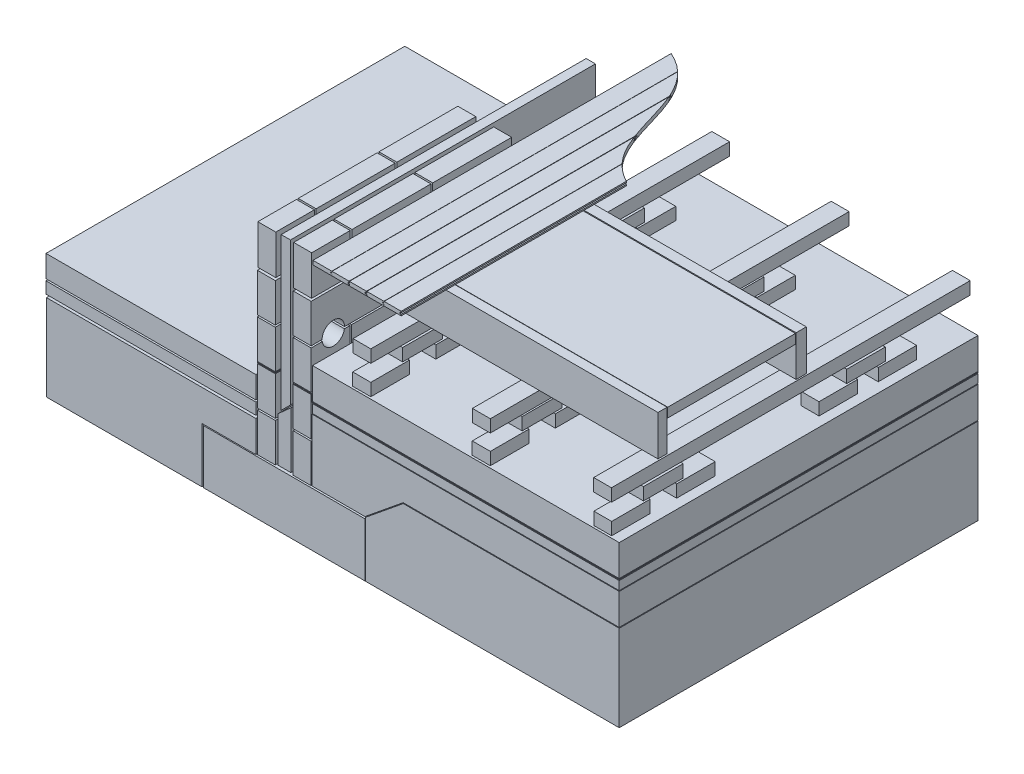
from build123d import *

# Parameters (mm, degrees)
SKETCH1_W         = 900
SKETCH1_H         = 300
EXTRUDE1_DEPTH    = 2000
SKETCH2_W         = 100
SKETCH2_H         = 215
EXTRUDE2_DEPTH    = 215
SKETCH4_W         = 100
SKETCH4_H         = 215
EXTRUDE3_DEPTH    = 440
SKETCH5_W         = 440
SKETCH5_H         = 215
EXTRUDE4_DEPTH    = 100
EXTRUDE4_2_DEPTH  = 100
EXTRUDE4_3_DEPTH  = 100
EXTRUDE4_4_DEPTH  = 100
EXTRUDE4_5_DEPTH  = 100
EXTRUDE4_6_DEPTH  = 100
EXTRUDE4_7_DEPTH  = 100
SKETCH8_W         = 100
SKETCH8_H         = 215
EXTRUDE5_DEPTH    = 215
SKETCH9_W         = 440
SKETCH9_H         = 215
EXTRUDE6_DEPTH    = 100
EXTRUDE6_2_DEPTH  = 100
EXTRUDE6_3_DEPTH  = 100
EXTRUDE6_4_DEPTH  = 100
EXTRUDE6_5_DEPTH  = 100
EXTRUDE6_6_DEPTH  = 100
SKETCH10_W        = 100
SKETCH10_H        = 215
EXTRUDE7_DEPTH    = 215
SKETCH12_W        = 440
SKETCH12_H        = 215
EXTRUDE9_DEPTH    = 100
SKETCH13_W        = 440
SKETCH13_H        = 215
EXTRUDE10_DEPTH   = 100
EXTRUDE10_2_DEPTH = 100
EXTRUDE10_3_DEPTH = 100
EXTRUDE10_4_DEPTH = 100
EXTRUDE10_5_DEPTH = 100
EXTRUDE10_6_DEPTH = 100
EXTRUDE10_7_DEPTH = 100
SKETCH14_W        = 215
SKETCH14_H        = 215
EXTRUDE11_DEPTH   = 100
SKETCH14_W_2      = 440
EXTRUDE11_2_DEPTH = 100
EXTRUDE11_3_DEPTH = 100
EXTRUDE11_4_DEPTH = 100
EXTRUDE11_5_DEPTH = 100
EXTRUDE11_6_DEPTH = 100
EXTRUDE11_7_DEPTH = 100
EXTRUDE12_DEPTH   = 1700
EXTRUDE13_DEPTH   = 1904
SKETCH17_W        = 1413.985383722
SKETCH17_H        = 300
EXTRUDE14_DEPTH   = 2000
EXTRUDE15_DEPTH   = 2000
EXTRUDE16_DEPTH   = 2000
SKETCH20_W        = 1710.022309895
SKETCH20_H        = 48.486443179
EXTRUDE17_DEPTH   = 2000
EXTRUDE20_DEPTH   = 2000
SKETCH25_W        = 1709.651265891
SKETCH25_H        = 173.596548359
EXTRUDE21_DEPTH   = 2000
SKETCH28_W        = 100.850874101
SKETCH28_H        = 69.438306757
EXTRUDE23_DEPTH   = 215
SKETCH28_W_2      = 100.8508741
EXTRUDE23_2_DEPTH = 215
SKETCH28_W_3      = 99.022104529
EXTRUDE23_3_DEPTH = 215
SKETCH29_W        = 215.093731923
SKETCH29_H        = 69.021592617
EXTRUDE24_DEPTH   = 100
SKETCH29_W_2      = 215.093731922
EXTRUDE24_2_DEPTH = 100
SKETCH29_W_3      = 213.840709242
EXTRUDE24_3_DEPTH = 100
SKETCH30_W        = 215.093731923
SKETCH30_H        = 69.021592617
EXTRUDE25_DEPTH   = 100
SKETCH30_W_2      = 215.093731922
EXTRUDE25_2_DEPTH = 100
SKETCH30_W_3      = 213.840709242
EXTRUDE25_3_DEPTH = 100
SKETCH31_W        = 215.093731923
SKETCH31_H        = 69.021592617
EXTRUDE26_DEPTH   = 100
SKETCH31_W_2      = 215.093731922
EXTRUDE26_2_DEPTH = 100
SKETCH31_W_3      = 213.840709242
EXTRUDE26_3_DEPTH = 100
SKETCH32_W        = 221.152710287
SKETCH32_H        = 69.423377302
EXTRUDE27_DEPTH   = 100
SKETCH32_W_2      = 215.093731923
EXTRUDE27_2_DEPTH = 100
SKETCH33_W        = 221.152710287
SKETCH33_H        = 69.423377302
EXTRUDE28_DEPTH   = 100
SKETCH33_W_2      = 215.093731923
EXTRUDE28_2_DEPTH = 100
SKETCH34_W        = 221.152710287
SKETCH34_H        = 69.423377302
EXTRUDE29_DEPTH   = 100
SKETCH34_W_2      = 215.093731923
EXTRUDE29_2_DEPTH = 100
SKETCH35_W        = 98.815369604
SKETCH35_H        = 70.169832547
EXTRUDE30_DEPTH   = 2000
SKETCH36_W        = 100
SKETCH36_H        = 69.118426671
EXTRUDE31_DEPTH   = 2000
SKETCH37_W        = 99.003383098
SKETCH37_H        = 69.983893454
EXTRUDE32_DEPTH   = 2000
SKETCH39_W        = 215
SKETCH39_H        = 220
EXTRUDE33_DEPTH   = 100
SKETCH39_W_2      = 440
EXTRUDE33_2_DEPTH = 100
EXTRUDE33_3_DEPTH = 100
SKETCH40_W        = 215
SKETCH40_H        = 220
EXTRUDE34_DEPTH   = 100
SKETCH40_W_2      = 440
EXTRUDE34_2_DEPTH = 100
EXTRUDE34_3_DEPTH = 100
EXTRUDE35_DEPTH   = 2000
SKETCH42_W        = 1169.696878952
SKETCH42_H        = 64.120703773
EXTRUDE36_DEPTH   = 2000
SKETCH43_W        = 1169.696878952
SKETCH43_H        = 122.428506493
EXTRUDE37_DEPTH   = 2000
SKETCH44_W        = 99.536047724
SKETCH44_H        = 4.404249899
EXTRUDE38_DEPTH   = 1790
SKETCH45_W        = 51.140184624
SKETCH45_H        = 224.448588069
EXTRUDE39_DEPTH   = 1665
SKETCH46_W        = 56.71894741
SKETCH46_H        = 225.831490573
EXTRUDE40_DEPTH   = 1665
EXTRUDE42_DEPTH   = 1997.41241
EXTRUDE42_2_DEPTH = 1997.41241
EXTRUDE42_3_DEPTH = 1997.41241
EXTRUDE42_4_DEPTH = 1997.41241
EXTRUDE42_5_DEPTH = 1997.41241
EXTRUDE43_DEPTH   = 23
SKETCH49_W        = 711.82785676
SKETCH49_H        = 52.340283585
EXTRUDE44_DEPTH   = 1665
SKETCH50_R        = 62.59843346
EXTRUDE46_DEPTH   = 300
EXTRUDE47_START   = -826.7125
EXTRUDE47_DEPTH   = 826.7125


with BuildPart() as part:
    # Sketch1 → Extrude1 (new body)
    with BuildSketch(Plane.XY):
        with Locations((450, 150)):
            Rectangle(SKETCH1_W, SKETCH1_H)
    extrude(amount=-EXTRUDE1_DEPTH)


with BuildPart() as body_2:
    # Sketch2 → Extrude2 (new body)
    with BuildSketch(Plane.XY):
        with Locations((350, 417.5)):
            Rectangle(SKETCH2_W, SKETCH2_H)
    extrude(amount=-EXTRUDE2_DEPTH)


with BuildPart() as body_3:
    # Sketch4 → Extrude3 (new body)
    with BuildSketch(Plane.XY):
        with Locations((350, 642.5)):
            Rectangle(SKETCH4_W, SKETCH4_H)
    extrude(amount=-EXTRUDE3_DEPTH)


with BuildPart() as body_4:
    # Sketch5 → Extrude4 (new body)
    with BuildSketch(Plane(origin=(400, 0, 0), x_dir=(0, 0, -1), z_dir=(1, 0, 0))):
        with Locations((445, 417.5)):
            Rectangle(SKETCH5_W, SKETCH5_H)
    extrude(amount=-EXTRUDE4_DEPTH)


with BuildPart() as body_5:
    # Sketch5 → Extrude4 2 (new body)
    with BuildSketch(Plane(origin=(400, 0, 0), x_dir=(0, 0, -1), z_dir=(1, 0, 0))):
        with Locations((670, 642.5)):
            Rectangle(SKETCH5_W, SKETCH5_H)
    extrude(amount=-EXTRUDE4_2_DEPTH)


with BuildPart() as body_6:
    # Sketch5 → Extrude4 3 (new body)
    with BuildSketch(Plane(origin=(400, 0, 0), x_dir=(0, 0, -1), z_dir=(1, 0, 0))):
        with Locations((895, 417.5)):
            Rectangle(SKETCH5_W, SKETCH5_H)
    extrude(amount=-EXTRUDE4_3_DEPTH)


with BuildPart() as body_7:
    # Sketch5 → Extrude4 4 (new body)
    with BuildSketch(Plane(origin=(400, 0, 0), x_dir=(0, 0, -1), z_dir=(1, 0, 0))):
        with Locations((1120, 642.5)):
            Rectangle(SKETCH5_W, SKETCH5_H)
    extrude(amount=-EXTRUDE4_4_DEPTH)


with BuildPart() as body_8:
    # Sketch5 → Extrude4 5 (new body)
    with BuildSketch(Plane(origin=(400, 0, 0), x_dir=(0, 0, -1), z_dir=(1, 0, 0))):
        with Locations((1345, 417.5)):
            Rectangle(SKETCH5_W, SKETCH5_H)
    extrude(amount=-EXTRUDE4_5_DEPTH)


with BuildPart() as body_9:
    # Sketch5 → Extrude4 6 (new body)
    with BuildSketch(Plane(origin=(400, 0, 0), x_dir=(0, 0, -1), z_dir=(1, 0, 0))):
        with Locations((1570, 642.5)):
            Rectangle(SKETCH5_W, SKETCH5_H)
    extrude(amount=-EXTRUDE4_6_DEPTH)


with BuildPart() as body_10:
    # Sketch5 → Extrude4 7 (new body)
    with BuildSketch(Plane(origin=(400, 0, 0), x_dir=(0, 0, -1), z_dir=(1, 0, 0))):
        with Locations((1795, 417.5)):
            Rectangle(SKETCH5_W, SKETCH5_H)
    extrude(amount=-EXTRUDE4_7_DEPTH)


with BuildPart() as body_11:
    # Sketch8 → Extrude5 (new body)
    with BuildSketch(Plane.XY):
        with Locations((350, 867.5)):
            Rectangle(SKETCH8_W, SKETCH8_H)
    extrude(amount=-EXTRUDE5_DEPTH)


with BuildPart() as body_12:
    # Sketch9 → Extrude6 (new body)
    with BuildSketch(Plane(origin=(400, 0, 0), x_dir=(0, 0, -1), z_dir=(1, 0, 0))):
        with Locations((445, 867.5)):
            Rectangle(SKETCH9_W, SKETCH9_H)
    extrude(amount=-EXTRUDE6_DEPTH)


with BuildPart() as body_13:
    # Sketch9 → Extrude6 2 (new body)
    with BuildSketch(Plane(origin=(400, 0, 0), x_dir=(0, 0, -1), z_dir=(1, 0, 0))):
        with Locations((895, 867.5)):
            Rectangle(SKETCH9_W, SKETCH9_H)
    extrude(amount=-EXTRUDE6_2_DEPTH)


with BuildPart() as body_14:
    # Sketch9 → Extrude6 3 (new body)
    with BuildSketch(Plane(origin=(400, 0, 0), x_dir=(0, 0, -1), z_dir=(1, 0, 0))):
        with Locations((220, 1092.5)):
            Rectangle(SKETCH9_W, SKETCH9_H)
    extrude(amount=-EXTRUDE6_3_DEPTH)


with BuildPart() as body_15:
    # Sketch9 → Extrude6 4 (new body)
    with BuildSketch(Plane(origin=(400, 0, 0), x_dir=(0, 0, -1), z_dir=(1, 0, 0))):
        with Locations((670, 1092.5)):
            Rectangle(SKETCH9_W, SKETCH9_H)
    extrude(amount=-EXTRUDE6_4_DEPTH)


with BuildPart() as body_16:
    # Sketch9 → Extrude6 5 (new body)
    with BuildSketch(Plane(origin=(400, 0, 0), x_dir=(0, 0, -1), z_dir=(1, 0, 0))):
        with Locations((1345, 867.5)):
            Rectangle(SKETCH9_W, SKETCH9_H)
    extrude(amount=-EXTRUDE6_5_DEPTH)


with BuildPart() as body_17:
    # Sketch9 → Extrude6 6 (new body)
    with BuildSketch(Plane(origin=(400, 0, 0), x_dir=(0, 0, -1), z_dir=(1, 0, 0))):
        with Locations((1120, 1092.5)):
            Rectangle(SKETCH9_W, SKETCH9_H)
    extrude(amount=-EXTRUDE6_6_DEPTH)


with BuildPart() as body_18:
    # Sketch10 → Extrude7 (new body)
    with BuildSketch(Plane.XY):
        with Locations((550, 417.5)):
            Rectangle(SKETCH10_W, SKETCH10_H)
    extrude(amount=-EXTRUDE7_DEPTH)


with BuildPart() as body_19:
    # Sketch12 → Extrude9 (new body)
    with BuildSketch(Plane(origin=(600, 0, 0), x_dir=(0, 0, -1), z_dir=(1, 0, 0))):
        with Locations((445, 417.5)):
            Rectangle(SKETCH12_W, SKETCH12_H)
    extrude(amount=-EXTRUDE9_DEPTH)


with BuildPart() as body_20:
    # Sketch13 → Extrude10 (new body)
    with BuildSketch(Plane(origin=(600, 0, 0), x_dir=(0, 0, -1), z_dir=(1, 0, 0))):
        with Locations((895, 417.5)):
            Rectangle(SKETCH13_W, SKETCH13_H)
    extrude(amount=-EXTRUDE10_DEPTH)


with BuildPart() as body_21:
    # Sketch13 → Extrude10 2 (new body)
    with BuildSketch(Plane(origin=(600, 0, 0), x_dir=(0, 0, -1), z_dir=(1, 0, 0))):
        with Locations((1345, 417.5)):
            Rectangle(SKETCH13_W, SKETCH13_H)
    extrude(amount=-EXTRUDE10_2_DEPTH)


with BuildPart() as body_22:
    # Sketch13 → Extrude10 3 (new body)
    with BuildSketch(Plane(origin=(600, 0, 0), x_dir=(0, 0, -1), z_dir=(1, 0, 0))):
        with Locations((1795, 417.5)):
            Rectangle(SKETCH13_W, SKETCH13_H)
    extrude(amount=-EXTRUDE10_3_DEPTH)


with BuildPart() as body_23:
    # Sketch13 → Extrude10 4 (new body)
    with BuildSketch(Plane(origin=(600, 0, 0), x_dir=(0, 0, -1), z_dir=(1, 0, 0))):
        with Locations((1570, 642.5)):
            Rectangle(SKETCH13_W, SKETCH13_H)
    extrude(amount=-EXTRUDE10_4_DEPTH)


with BuildPart() as body_24:
    # Sketch13 → Extrude10 5 (new body)
    with BuildSketch(Plane(origin=(600, 0, 0), x_dir=(0, 0, -1), z_dir=(1, 0, 0))):
        with Locations((1120, 642.5)):
            Rectangle(SKETCH13_W, SKETCH13_H)
    extrude(amount=-EXTRUDE10_5_DEPTH)


with BuildPart() as body_25:
    # Sketch13 → Extrude10 6 (new body)
    with BuildSketch(Plane(origin=(600, 0, 0), x_dir=(0, 0, -1), z_dir=(1, 0, 0))):
        with Locations((670, 642.5)):
            Rectangle(SKETCH13_W, SKETCH13_H)
    extrude(amount=-EXTRUDE10_6_DEPTH)


with BuildPart() as body_26:
    # Sketch13 → Extrude10 7 (new body)
    with BuildSketch(Plane(origin=(600, 0, 0), x_dir=(0, 0, -1), z_dir=(1, 0, 0))):
        with Locations((220, 642.5)):
            Rectangle(SKETCH13_W, SKETCH13_H)
    extrude(amount=-EXTRUDE10_7_DEPTH)


with BuildPart() as body_27:
    # Sketch14 → Extrude11 (new body)
    with BuildSketch(Plane(origin=(600, 0, 0), x_dir=(0, 0, -1), z_dir=(1, 0, 0))):
        with Locations((107.5, 867.5)):
            Rectangle(SKETCH14_W, SKETCH14_H)
    extrude(amount=-EXTRUDE11_DEPTH)


with BuildPart() as body_28:
    # Sketch14 → Extrude11 2 (new body)
    with BuildSketch(Plane(origin=(600, 0, 0), x_dir=(0, 0, -1), z_dir=(1, 0, 0))):
        with Locations((445, 867.5)):
            Rectangle(SKETCH14_W_2, SKETCH14_H)
    extrude(amount=-EXTRUDE11_2_DEPTH)


with BuildPart() as body_29:
    # Sketch14 → Extrude11 3 (new body)
    with BuildSketch(Plane(origin=(600, 0, 0), x_dir=(0, 0, -1), z_dir=(1, 0, 0))):
        with Locations((895, 867.5)):
            Rectangle(SKETCH14_W_2, SKETCH14_H)
    extrude(amount=-EXTRUDE11_3_DEPTH)


with BuildPart() as body_30:
    # Sketch14 → Extrude11 4 (new body)
    with BuildSketch(Plane(origin=(600, 0, 0), x_dir=(0, 0, -1), z_dir=(1, 0, 0))):
        with Locations((1345, 867.5)):
            Rectangle(SKETCH14_W_2, SKETCH14_H)
    extrude(amount=-EXTRUDE11_4_DEPTH)


with BuildPart() as body_31:
    # Sketch14 → Extrude11 5 (new body)
    with BuildSketch(Plane(origin=(600, 0, 0), x_dir=(0, 0, -1), z_dir=(1, 0, 0))):
        with Locations((1120, 1092.5)):
            Rectangle(SKETCH14_W_2, SKETCH14_H)
    extrude(amount=-EXTRUDE11_5_DEPTH)


with BuildPart() as body_32:
    # Sketch14 → Extrude11 6 (new body)
    with BuildSketch(Plane(origin=(600, 0, 0), x_dir=(0, 0, -1), z_dir=(1, 0, 0))):
        with Locations((670, 1092.5)):
            Rectangle(SKETCH14_W_2, SKETCH14_H)
    extrude(amount=-EXTRUDE11_6_DEPTH)


with BuildPart() as body_33:
    # Sketch14 → Extrude11 7 (new body)
    with BuildSketch(Plane(origin=(600, 0, 0), x_dir=(0, 0, -1), z_dir=(1, 0, 0))):
        with Locations((220, 1092.5)):
            Rectangle(SKETCH14_W_2, SKETCH14_H)
    extrude(amount=-EXTRUDE11_7_DEPTH)


with BuildPart() as body_34:
    # Sketch15 → Extrude12 (new body)
    with BuildSketch(Plane.XY):
        Polygon((484.508968927, 1198.97710352), (484.508968927, 641.903747983), (432.745515536, 590.140294592), (432.745515536, 1208.668773772), (432.745515536, 1438.668773772), (484.508968927, 1438.668773772), align=None)
    extrude(amount=-EXTRUDE12_DEPTH)


with BuildPart() as body_35:
    # Sketch16 → Extrude13 (new body)
    with BuildSketch(Plane.XY):
        Polygon((486.973895279, 629.579116223), (486.973895279, 316.533469528), (415.491031073, 316.533469528), (415.491031073, 565.491031073), align=None)
    extrude(amount=-EXTRUDE13_DEPTH)


with BuildPart() as body_36:
    # Sketch17 → Extrude14 (new body)
    with BuildSketch(Plane.XY):
        with Locations((1610.098395187, 150)):
            Rectangle(SKETCH17_W, SKETCH17_H)
    extrude(amount=-EXTRUDE14_DEPTH)

    # Sketch19 → Extrude16 (add)
    with BuildSketch(Plane.XY):
        Polygon((2317.091087048, 300), (2317.091087048, 480.344649525), (1113.200201106, 480.344649525), (903.105703326, 308.910636728), (903.105703326, 300), align=None)
    extrude(amount=-EXTRUDE16_DEPTH)


with BuildPart() as body_37:
    # Sketch18 → Extrude15 (new body)
    with BuildSketch(Plane.XY):
        Polygon((603.819735273, 310.918015637), (603.819735273, 658.054501993), (2317.091087048, 658.054501993), (2317.091087048, 484.486258815), (1112.868953541, 484.486258815), (899.810331569, 310.918015637), align=None)
    extrude(amount=-EXTRUDE15_DEPTH)


with BuildPart() as body_38:
    # Sketch20 → Extrude17 (new body)
    with BuildSketch(Plane.XY):
        with Locations((1462.079932101, 686.091779508)):
            Rectangle(SKETCH20_W, SKETCH20_H)
    extrude(amount=-EXTRUDE17_DEPTH)


with BuildPart() as body_39:
    # Sketch24 → Extrude20 (new body)
    with BuildSketch(Plane.XY):
        Polygon((499.45439356, 757.377098765), (605.597775649, 757.377098765), (605.597775649, 718.064735028), (2317.091087048, 718.064735028), (2317.091087048, 714.421815937), (601.875334892, 714.421815937), (601.875334892, 752.452906693), (499.45439356, 752.452906693), align=None)
    extrude(amount=-EXTRUDE20_DEPTH)


with BuildPart() as body_40:
    # Sketch25 → Extrude21 (new body)
    with BuildSketch(Plane.XY):
        with Locations((1462.265454103, 807.033006779)):
            Rectangle(SKETCH25_W, SKETCH25_H)
    extrude(amount=-EXTRUDE21_DEPTH)


with BuildPart() as body_41:
    # Sketch28 → Extrude23 (new body)
    with BuildSketch(Plane.XY):
        with Locations((881.930082047, 940.315985757)):
            Rectangle(SKETCH28_W, SKETCH28_H)
    extrude(amount=-EXTRUDE23_DEPTH)


with BuildPart() as body_42:
    # Sketch28 → Extrude23 2 (new body)
    with BuildSketch(Plane.XY):
        with Locations((1548.207168316, 940.315985757)):
            Rectangle(SKETCH28_W_2, SKETCH28_H)
    extrude(amount=-EXTRUDE23_2_DEPTH)


with BuildPart() as body_43:
    # Sketch28 → Extrude23 3 (new body)
    with BuildSketch(Plane.XY):
        with Locations((2225.377939836, 940.315985757)):
            Rectangle(SKETCH28_W_3, SKETCH28_H)
    extrude(amount=-EXTRUDE23_3_DEPTH)


with BuildPart() as body_44:
    # Sketch29 → Extrude24 (new body)
    with BuildSketch(Plane(origin=(2274.8889921, 0, 0), x_dir=(0, 0, -1), z_dir=(1, 0, 0))):
        with Locations((469.765670193, 940.489203692)):
            Rectangle(SKETCH29_W, SKETCH29_H)
    extrude(amount=-EXTRUDE24_DEPTH)


with BuildPart() as body_45:
    # Sketch29 → Extrude24 2 (new body)
    with BuildSketch(Plane(origin=(2274.8889921, 0, 0), x_dir=(0, 0, -1), z_dir=(1, 0, 0))):
        with Locations((1263.49183588, 940.489203692)):
            Rectangle(SKETCH29_W_2, SKETCH29_H)
    extrude(amount=-EXTRUDE24_2_DEPTH)


with BuildPart() as body_46:
    # Sketch29 → Extrude24 3 (new body)
    with BuildSketch(Plane(origin=(2274.8889921, 0, 0), x_dir=(0, 0, -1), z_dir=(1, 0, 0))):
        with Locations((1593.079645379, 940.489203692)):
            Rectangle(SKETCH29_W_3, SKETCH29_H)
    extrude(amount=-EXTRUDE24_3_DEPTH)


with BuildPart() as body_47:
    # Sketch30 → Extrude25 (new body)
    with BuildSketch(Plane(origin=(1598.632605366, 0, 0), x_dir=(0, 0, -1), z_dir=(1, 0, 0))):
        with Locations((469.765670193, 940.489203692)):
            Rectangle(SKETCH30_W, SKETCH30_H)
    extrude(amount=-EXTRUDE25_DEPTH)


with BuildPart() as body_48:
    # Sketch30 → Extrude25 2 (new body)
    with BuildSketch(Plane(origin=(1598.632605366, 0, 0), x_dir=(0, 0, -1), z_dir=(1, 0, 0))):
        with Locations((1263.49183588, 940.489203692)):
            Rectangle(SKETCH30_W_2, SKETCH30_H)
    extrude(amount=-EXTRUDE25_2_DEPTH)


with BuildPart() as body_49:
    # Sketch30 → Extrude25 3 (new body)
    with BuildSketch(Plane(origin=(1598.632605366, 0, 0), x_dir=(0, 0, -1), z_dir=(1, 0, 0))):
        with Locations((1593.079645379, 940.489203692)):
            Rectangle(SKETCH30_W_3, SKETCH30_H)
    extrude(amount=-EXTRUDE25_3_DEPTH)


with BuildPart() as body_50:
    # Sketch31 → Extrude26 (new body)
    with BuildSketch(Plane(origin=(932.355519097, 0, 0), x_dir=(0, 0, -1), z_dir=(1, 0, 0))):
        with Locations((469.765670193, 940.489203692)):
            Rectangle(SKETCH31_W, SKETCH31_H)
    extrude(amount=-EXTRUDE26_DEPTH)


with BuildPart() as body_51:
    # Sketch31 → Extrude26 2 (new body)
    with BuildSketch(Plane(origin=(932.355519097, 0, 0), x_dir=(0, 0, -1), z_dir=(1, 0, 0))):
        with Locations((1263.49183588, 940.489203692)):
            Rectangle(SKETCH31_W_2, SKETCH31_H)
    extrude(amount=-EXTRUDE26_2_DEPTH)


with BuildPart() as body_52:
    # Sketch31 → Extrude26 3 (new body)
    with BuildSketch(Plane(origin=(932.355519097, 0, 0), x_dir=(0, 0, -1), z_dir=(1, 0, 0))):
        with Locations((1593.079645379, 940.489203692)):
            Rectangle(SKETCH31_W_3, SKETCH31_H)
    extrude(amount=-EXTRUDE26_3_DEPTH)


with BuildPart() as body_53:
    # Sketch32 → Extrude27 (new body)
    with BuildSketch(Plane(origin=(2274.8889921, 0, 0), x_dir=(0, 0, -1), z_dir=(1, 0, 0))):
        with Locations((287.996319273, 1019.711688651)):
            Rectangle(SKETCH32_W, SKETCH32_H)
    extrude(amount=-EXTRUDE27_DEPTH)


with BuildPart() as body_54:
    # Sketch32 → Extrude27 2 (new body)
    with BuildSketch(Plane(origin=(2274.8889921, 0, 0), x_dir=(0, 0, -1), z_dir=(1, 0, 0))):
        with Locations((1417.995784163, 1019.711688651)):
            Rectangle(SKETCH32_W_2, SKETCH32_H)
    extrude(amount=-EXTRUDE27_2_DEPTH)


with BuildPart() as body_55:
    # Sketch33 → Extrude28 (new body)
    with BuildSketch(Plane(origin=(1598.632605366, 0, 0), x_dir=(0, 0, -1), z_dir=(1, 0, 0))):
        with Locations((287.996319273, 1019.711688651)):
            Rectangle(SKETCH33_W, SKETCH33_H)
    extrude(amount=-EXTRUDE28_DEPTH)


with BuildPart() as body_56:
    # Sketch33 → Extrude28 2 (new body)
    with BuildSketch(Plane(origin=(1598.632605366, 0, 0), x_dir=(0, 0, -1), z_dir=(1, 0, 0))):
        with Locations((1417.995784163, 1019.711688651)):
            Rectangle(SKETCH33_W_2, SKETCH33_H)
    extrude(amount=-EXTRUDE28_2_DEPTH)


with BuildPart() as body_57:
    # Sketch34 → Extrude29 (new body)
    with BuildSketch(Plane(origin=(932.355519097, 0, 0), x_dir=(0, 0, -1), z_dir=(1, 0, 0))):
        with Locations((287.996319273, 1019.711688651)):
            Rectangle(SKETCH34_W, SKETCH34_H)
    extrude(amount=-EXTRUDE29_DEPTH)


with BuildPart() as body_58:
    # Sketch34 → Extrude29 2 (new body)
    with BuildSketch(Plane(origin=(932.355519097, 0, 0), x_dir=(0, 0, -1), z_dir=(1, 0, 0))):
        with Locations((1417.995784163, 1019.711688651)):
            Rectangle(SKETCH34_W_2, SKETCH34_H)
    extrude(amount=-EXTRUDE29_2_DEPTH)


with BuildPart() as body_59:
    # Sketch35 → Extrude30 (new body)
    with BuildSketch(Plane.XY):
        with Locations((2224.296676902, 1101.849831726)):
            Rectangle(SKETCH35_W, SKETCH35_H)
    extrude(amount=-EXTRUDE30_DEPTH)


with BuildPart() as body_60:
    # Sketch36 → Extrude31 (new body)
    with BuildSketch(Plane.XY):
        with Locations((1548.632605366, 1098.027996737)):
            Rectangle(SKETCH36_W, SKETCH36_H)
    extrude(amount=-EXTRUDE31_DEPTH)


with BuildPart() as body_61:
    # Sketch37 → Extrude32 (new body)
    with BuildSketch(Plane.XY):
        with Locations((882.853827548, 1101.761191997)):
            Rectangle(SKETCH37_W, SKETCH37_H)
    extrude(amount=-EXTRUDE32_DEPTH)


with BuildPart() as body_62:
    # Sketch39 → Extrude33 (new body)
    with BuildSketch(Plane.ZY.offset(-300)):
        with Locations((-110.087589967, 1323.131583102)):
            Rectangle(SKETCH39_W, SKETCH39_H)
    extrude(amount=-EXTRUDE33_DEPTH)


with BuildPart() as body_63:
    # Sketch39 → Extrude33 2 (new body)
    with BuildSketch(Plane.ZY.offset(-300)):
        with Locations((-447.587589967, 1323.131583102)):
            Rectangle(SKETCH39_W_2, SKETCH39_H)
    extrude(amount=-EXTRUDE33_2_DEPTH)


with BuildPart() as body_64:
    # Sketch39 → Extrude33 3 (new body)
    with BuildSketch(Plane.ZY.offset(-300)):
        with Locations((-897.587589967, 1323.131583102)):
            Rectangle(SKETCH39_W_2, SKETCH39_H)
    extrude(amount=-EXTRUDE33_3_DEPTH)


with BuildPart() as body_65:
    # Sketch40 → Extrude34 (new body)
    with BuildSketch(Plane(origin=(600, 0, 0), x_dir=(0, 0, -1), z_dir=(1, 0, 0))):
        with Locations((110.087589967, 1323.131583102)):
            Rectangle(SKETCH40_W, SKETCH40_H)
    extrude(amount=-EXTRUDE34_DEPTH)


with BuildPart() as body_66:
    # Sketch40 → Extrude34 2 (new body)
    with BuildSketch(Plane(origin=(600, 0, 0), x_dir=(0, 0, -1), z_dir=(1, 0, 0))):
        with Locations((447.587589967, 1323.131583102)):
            Rectangle(SKETCH40_W_2, SKETCH40_H)
    extrude(amount=-EXTRUDE34_2_DEPTH)


with BuildPart() as body_67:
    # Sketch40 → Extrude34 3 (new body)
    with BuildSketch(Plane(origin=(600, 0, 0), x_dir=(0, 0, -1), z_dir=(1, 0, 0))):
        with Locations((897.587589967, 1323.131583102)):
            Rectangle(SKETCH40_W_2, SKETCH40_H)
    extrude(amount=-EXTRUDE34_3_DEPTH)


with BuildPart() as body_68:
    # Sketch41 → Extrude35 (new body)
    with BuildSketch(Plane.XY):
        Polygon((291.463587408, 480.344649525), (-875.862486023, 480.344649525), (-875.862486023, 0), (-8.847153055, 0), (-8.847153055, 305.920722973), (291.463587408, 305.920722973), align=None)
    extrude(amount=-EXTRUDE35_DEPTH)


with BuildPart() as body_69:
    # Sketch42 → Extrude36 (new body)
    with BuildSketch(Plane.XY):
        with Locations((-293.384852068, 527.72293827)):
            Rectangle(SKETCH42_W, SKETCH42_H)
    extrude(amount=-EXTRUDE36_DEPTH)


with BuildPart() as body_70:
    # Sketch43 → Extrude37 (new body)
    with BuildSketch(Plane.XY):
        with Locations((-293.384852068, 631.1393991)):
            Rectangle(SKETCH43_W, SKETCH43_H)
    extrude(amount=-EXTRUDE37_DEPTH)


with BuildPart() as body_71:
    # Sketch44 → Extrude38 (new body)
    with BuildSketch(Plane.XY):
        with Locations((349.872639875, 755.437033677)):
            Rectangle(SKETCH44_W, SKETCH44_H)
    extrude(amount=-EXTRUDE38_DEPTH)


with BuildPart() as body_72:
    # Sketch45 → Extrude39 (new body)
    with BuildSketch(Plane(origin=(2273.704361704, 0, 0), x_dir=(0, 0, -1), z_dir=(1, 0, 0))):
        with Locations((285.133908646, 1258.333688999)):
            Rectangle(SKETCH45_W, SKETCH45_H)
    extrude(amount=-EXTRUDE39_DEPTH)


with BuildPart() as body_73:
    # Sketch46 → Extrude40 (new body)
    with BuildSketch(Plane(origin=(2273.704361704, 0, 0), x_dir=(0, 0, -1), z_dir=(1, 0, 0))):
        with Locations((1057.916842142, 1257.642237747)):
            Rectangle(SKETCH46_W, SKETCH46_H)
    extrude(amount=-EXTRUDE40_DEPTH)


with BuildPart() as body_74:
    # Sketch47 → Extrude42 (new body)
    with BuildSketch(Plane.XY.offset(-2.587589967)):
        Polygon((607.53732446, 1378.052032867), (712.157733562, 1378.052032867), (712.157733562, 1385.524919232), (704.684847197, 1385.524919232), (704.684847197, 1392.997805596), (712.157733562, 1392.997805596), (712.157733562, 1400.470691961), (607.53732446, 1400.470691961), align=None)
    extrude(amount=-EXTRUDE42_DEPTH)


with BuildPart() as body_75:
    # Sketch47 → Extrude42 2 (new body)
    with BuildSketch(Plane.XY.offset(-2.587589967)):
        Polygon((713.482963674, 1400.470691961), (713.482963674, 1391.501539203), (705.198413885, 1391.501539203), (705.198413885, 1386.189147754), (713.482963674, 1386.189147754), (713.482963674, 1378.052032867), (808.494921356, 1378.052032867), (808.494921356, 1385.524919232), (801.359704392, 1385.524919232), (801.359704392, 1392.997805596), (808.494921356, 1392.997805596), (808.494921356, 1400.470691961), align=None)
    extrude(amount=-EXTRUDE42_2_DEPTH)


with BuildPart() as body_76:
    # Sketch47 → Extrude42 3 (new body)
    with BuildSketch(Plane.XY.offset(-2.587589967)):
        Polygon((898.316838683, 1392.997805596), (905.452055648, 1392.997805596), (905.452055648, 1400.470691961), (810.440097966, 1400.470691961), (810.440097966, 1391.501539203), (802.155548176, 1391.501539203), (802.155548176, 1386.189147754), (810.440097966, 1386.189147754), (810.440097966, 1378.052032867), (905.452055648, 1378.052032867), (905.452055648, 1385.524919232), (898.316838683, 1385.524919232), align=None)
    extrude(amount=-EXTRUDE42_3_DEPTH)


with BuildPart() as body_77:
    # Sketch47 → Extrude42 4 (new body)
    with BuildSketch(Plane.XY.offset(-2.587589967)):
        Polygon((1002.613052767, 1392.997805596), (1002.613052767, 1400.470691961), (907.601095085, 1400.470691961), (907.601095085, 1391.501539203), (899.316545295, 1391.501539203), (899.316545295, 1386.189147754), (907.601095085, 1386.189147754), (907.601095085, 1378.052032867), (1002.613052767, 1378.052032867), (1002.613052767, 1385.524919232), (995.477835802, 1385.524919232), (995.477835802, 1392.997805596), align=None)
    extrude(amount=-EXTRUDE42_4_DEPTH)


with BuildPart() as body_78:
    # Sketch47 → Extrude42 5 (new body)
    with BuildSketch(Plane.XY.offset(-2.587589967)):
        Polygon((1091.992933001, 1392.997805596), (1099.128149966, 1392.997805596), (1099.128149966, 1400.470691961), (1004.116192284, 1400.470691961), (1004.116192284, 1391.501539203), (995.831642494, 1391.501539203), (995.831642494, 1386.189147754), (1004.116192284, 1386.189147754), (1004.116192284, 1378.052032867), (1099.128149966, 1378.052032867), (1099.128149966, 1385.524919232), (1091.992933001, 1385.524919232), align=None)
    extrude(amount=-EXTRUDE42_5_DEPTH)


with BuildPart() as extrude43_tool:
    # Sketch48 → Extrude43 (new body)
    with BuildSketch(Plane(origin=(0, 1400.470691961, 0), x_dir=(1, 0, 0), z_dir=(0, 1, 0))):
        with BuildLine():
            Line((605.597775649, 2000), (1099.128149966, 2000))
            Line((1099.128149966, 2000), (1099.128149966, 1257.342066979))
            add(Edge.make_bspline(
                [(605.597775649, 2000), (935.008387915, 1857.173619148), (794.95257872, 1415.85347792), (1099.128149966, 1257.342066979)],
                knots=[0, 0, 0, 0, 1, 1, 1, 1], degree=3))
        make_face()
    extrude(amount=-EXTRUDE43_DEPTH)


with BuildPart() as body_74_1:
    add(body_74.part)

    # Extrude43: cut by extrude43_tool
    add(extrude43_tool.part, mode=Mode.SUBTRACT)


with BuildPart() as body_75_1:
    add(body_75.part)

    # Extrude43: cut by extrude43_tool
    add(extrude43_tool.part, mode=Mode.SUBTRACT)


with BuildPart() as body_76_1:
    add(body_76.part)

    # Extrude43: cut by extrude43_tool
    add(extrude43_tool.part, mode=Mode.SUBTRACT)


with BuildPart() as body_77_1:
    add(body_77.part)

    # Extrude43: cut by extrude43_tool
    add(extrude43_tool.part, mode=Mode.SUBTRACT)


with BuildPart() as body_78_1:
    add(body_78.part)

    # Extrude43: cut by extrude43_tool
    add(extrude43_tool.part, mode=Mode.SUBTRACT)


with BuildPart() as body_79:
    # Sketch49 → Extrude44 (new body)
    with BuildSketch(Plane(origin=(2273.704361704, 0, 0), x_dir=(0, 0, -1), z_dir=(1, 0, 0))):
        with Locations((669.763700567, 1342.894691336)):
            Rectangle(SKETCH49_W, SKETCH49_H)
    extrude(amount=-EXTRUDE44_DEPTH)


with BuildPart() as extrude46_tool:
    # Sketch50 → Extrude46 (new body)
    with BuildSketch(Plane.ZY.offset(-300)):
        with Locations((-123.481976038, 985)):
            Circle(SKETCH50_R)
    extrude(amount=-EXTRUDE46_DEPTH)


with BuildPart() as body_11_1:
    add(body_11.part)

    # Extrude46: cut by extrude46_tool
    add(extrude46_tool.part, mode=Mode.SUBTRACT)


with BuildPart() as body_14_1:
    add(body_14.part)

    # Extrude46: cut by extrude46_tool
    add(extrude46_tool.part, mode=Mode.SUBTRACT)


with BuildPart() as body_27_1:
    add(body_27.part)

    # Extrude46: cut by extrude46_tool
    add(extrude46_tool.part, mode=Mode.SUBTRACT)


with BuildPart() as body_33_1:
    add(body_33.part)

    # Extrude46: cut by extrude46_tool
    add(extrude46_tool.part, mode=Mode.SUBTRACT)


with BuildPart() as body_34_1:
    add(body_34.part)

    # Extrude46: cut by extrude46_tool
    add(extrude46_tool.part, mode=Mode.SUBTRACT)


with BuildPart() as extrude47_tool:
    # Sketch51 → Extrude47 (new body)
    with BuildSketch(Plane.XY.offset(-259.563816334).offset(EXTRUDE47_START)):
        Polygon((608.704361704, 1370.557983033), (649.275952516, 1146.109394964), (608.704361704, 1146.109394964), align=None)
    extrude(amount=EXTRUDE47_DEPTH)


with BuildPart() as body_72_1:
    add(body_72.part)

    # Extrude47: cut by extrude47_tool
    add(extrude47_tool.part, mode=Mode.SUBTRACT)


with BuildPart() as body_73_1:
    add(body_73.part)

    # Extrude47: cut by extrude47_tool
    add(extrude47_tool.part, mode=Mode.SUBTRACT)


with BuildPart() as body_79_1:
    add(body_79.part)

    # Extrude47: cut by extrude47_tool
    add(extrude47_tool.part, mode=Mode.SUBTRACT)


solid = Compound([part.part, body_2.part, body_3.part, body_4.part, body_5.part, body_6.part, body_7.part, body_8.part, body_9.part, body_10.part, body_12.part, body_13.part, body_15.part, body_16.part, body_17.part, body_18.part, body_19.part, body_20.part, body_21.part, body_22.part, body_23.part, body_24.part, body_25.part, body_26.part, body_28.part, body_29.part, body_30.part, body_31.part, body_32.part, body_35.part, body_36.part, body_37.part, body_38.part, body_39.part, body_40.part, body_41.part, body_42.part, body_43.part, body_44.part, body_45.part, body_46.part, body_47.part, body_48.part, body_49.part, body_50.part, body_51.part, body_52.part, body_53.part, body_54.part, body_55.part, body_56.part, body_57.part, body_58.part, body_59.part, body_60.part, body_61.part, body_62.part, body_63.part, body_64.part, body_65.part, body_66.part, body_67.part, body_68.part, body_69.part, body_70.part, body_71.part, body_74_1.part, body_75_1.part, body_76_1.part, body_77_1.part, body_78_1.part, body_11_1.part, body_14_1.part, body_27_1.part, body_33_1.part, body_34_1.part, body_72_1.part, body_73_1.part, body_79_1.part])
